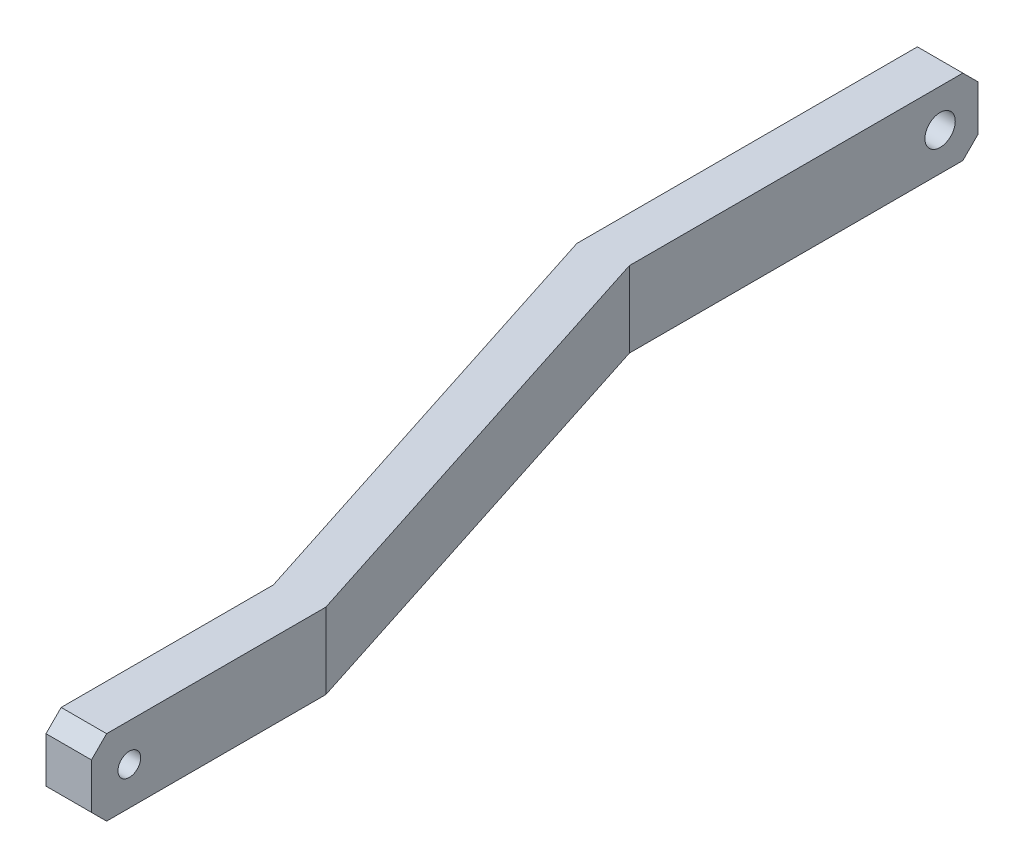
from build123d import *

# Parameters (mm, degrees)
BOSS_EXTRUDE1_DEPTH = 5
SKETCH3_R           = 0.75
CUT_EXTRUDE1_DEPTH  = 4
SKETCH4_R           = 1
CUT_EXTRUDE2_DEPTH  = 4
CHAMFER1_SIZE       = 1


with BuildPart() as part:
    # Sketch2 → Boss-Extrude1 (new body)
    with BuildSketch(Plane(origin=(0, 0, 0), x_dir=(1, 0, 0), z_dir=(0, 1, 0))):
        Polygon((0, 0), (0, 15.470692064), (-9.5, 45), (-9.5, 68), (-12.5, 68), (-12.5, 44.529307936), (-3, 15), (-3, 0), align=None)
    extrude(amount=BOSS_EXTRUDE1_DEPTH)

    # Sketch3 → Cut-Extrude1 (cut, through all)
    with BuildSketch(Plane.ZY.offset(3)):
        with Locations((-2.5, 2.5)):
            Circle(SKETCH3_R)
    extrude(amount=-CUT_EXTRUDE1_DEPTH, mode=Mode.SUBTRACT)

    # Sketch4 → Cut-Extrude2 (cut, through all)
    with BuildSketch(Plane(origin=(-9.5, 0, 0), x_dir=(0, 0, -1), z_dir=(1, 0, 0))):
        with Locations((65.5, 2.5)):
            Circle(SKETCH4_R)
    extrude(amount=-CUT_EXTRUDE2_DEPTH, mode=Mode.SUBTRACT)

    # Chamfer1
    chamfer1_edges = [part.edges().sort_by_distance(p)[0] for p in [
        (-1.5, 0, 0),
        (-11, 5, -68),
        (-1.5, 5, 0),
        (-11, 0, -68),
    ]]
    chamfer(chamfer1_edges, length=CHAMFER1_SIZE)


solid = part.part
